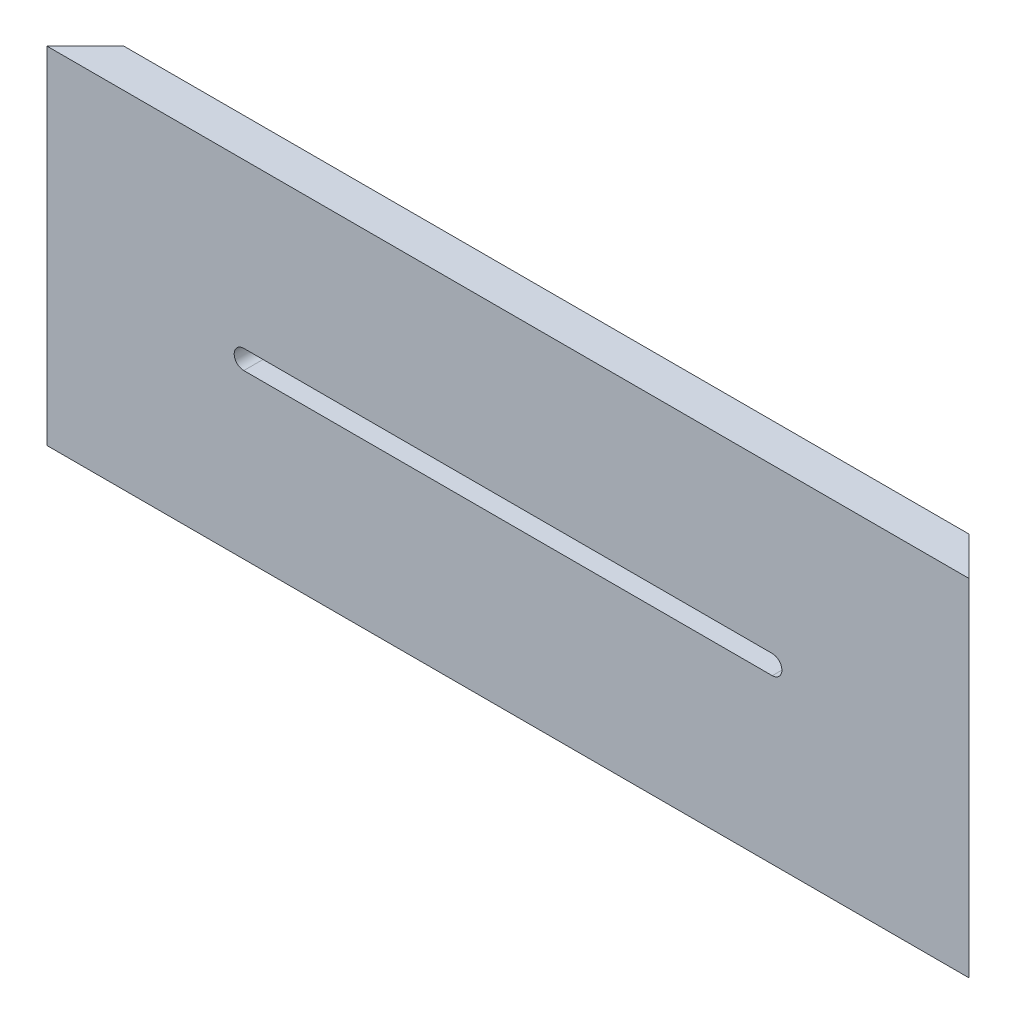
from build123d import *

# Parameters (mm, degrees)
SKETCH1_W           = 152.4
SKETCH1_H           = 57.15
BOSS_EXTRUDE1_DEPTH = 6.35
CUT_EXTRUDE1_DEPTH  = 7.35
CUT_EXTRUDE2_DEPTH  = 58.15
SKETCH4_W           = 3.175
SKETCH4_H           = 4.7625
CUT_EXTRUDE3_DEPTH  = 153.4
SKETCH5_W           = 3.175
SKETCH5_H           = 3.2512
CUT_EXTRUDE4_DEPTH  = 153.4
SKETCH6_R           = 2.3876
CUT_EXTRUDE5_DEPTH  = 5.08


with BuildPart() as part:
    # Sketch1 → Boss-Extrude1 (new body)
    with BuildSketch(Plane.XY):
        with Locations((76.2, 28.575)):
            Rectangle(SKETCH1_W, SKETCH1_H)
    extrude(amount=-BOSS_EXTRUDE1_DEPTH)

    # Sketch2 → Cut-Extrude1 (cut, through all)
    with BuildSketch(Plane.XY):
        with BuildLine():
            Line((32.5501, 30.1625), (119.8626, 30.1625))
            ThreePointArc((119.8626, 30.1625), (121.4501, 28.575), (119.8626, 26.9875))
            Line((119.8626, 26.9875), (32.5501, 26.9875))
            ThreePointArc((32.5501, 26.9875), (30.9626, 28.575), (32.5501, 30.1625))
        make_face()
    extrude(amount=-CUT_EXTRUDE1_DEPTH, mode=Mode.SUBTRACT)

    # Sketch3 → Cut-Extrude2 (cut, through all)
    with BuildSketch(Plane(origin=(0, 57.15, 0), x_dir=(1, 0, 0), z_dir=(0, 1, 0))):
        Polygon((152.4, 0), (146.05, 6.35), (152.4, 6.35), align=None)
        Polygon((0, 0), (6.35, 6.35), (0, 6.35), align=None)
    extrude(amount=-CUT_EXTRUDE2_DEPTH, mode=Mode.SUBTRACT)

    # Sketch4 → Cut-Extrude3 (cut, through all)
    with BuildSketch(Plane(origin=(0, 0, 0), x_dir=(0, 0, -1), z_dir=(1, 0, 0))):
        with Locations((4.7625, 43.97375)):
            Rectangle(SKETCH4_W, SKETCH4_H)
    extrude(amount=CUT_EXTRUDE3_DEPTH, mode=Mode.SUBTRACT)

    # Sketch5 → Cut-Extrude4 (cut, through all)
    with BuildSketch(Plane(origin=(0, 0, 0), x_dir=(0, 0, -1), z_dir=(1, 0, 0))):
        with Locations((4.7625, 6.3881)):
            Rectangle(SKETCH5_W, SKETCH5_H)
    extrude(amount=CUT_EXTRUDE4_DEPTH, mode=Mode.SUBTRACT)

    # Sketch6 → Cut-Extrude5 (cut)
    with BuildSketch(Plane(origin=(0, 0, -6.35), x_dir=(-1, 0, 0), z_dir=(0, 0, -1))):
        with Locations((-9.652, 49.911)):
            Circle(SKETCH6_R)
    extrude(amount=-CUT_EXTRUDE5_DEPTH, mode=Mode.SUBTRACT)


solid = part.part
